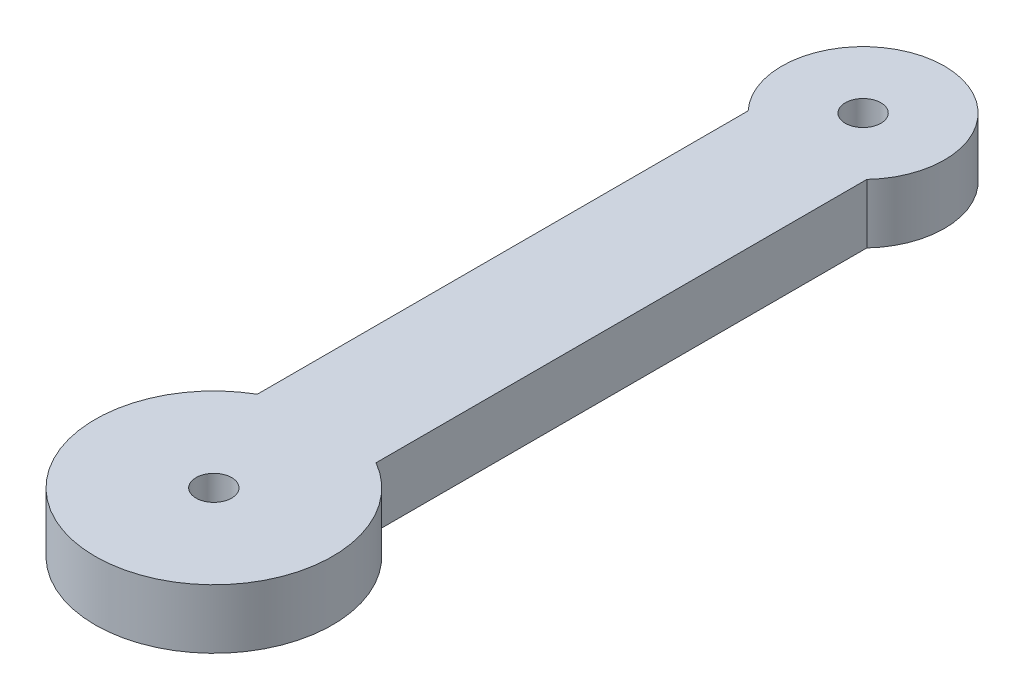
from build123d import *

# Parameters (mm, degrees)
SKETCH2_R           = 0.75
BOSS_EXTRUDE1_DEPTH = 2.5


with BuildPart() as part:
    # Sketch2 → Boss-Extrude1 (new body)
    with BuildSketch(Plane(origin=(0, 0, 0), x_dir=(1, 0, 0), z_dir=(0, 1, 0))):
        with BuildLine():
            Line((-2.5, 25), (-2.5, 4.330127019))
            ThreePointArc((-2.5, 4.330127019), (0, -5), (2.5, 4.330127019))
            Line((2.5, 4.330127019), (2.5, 25))
            ThreePointArc((2.5, 25), (0, 30.768904363), (-2.5, 25))
        make_face()
        Circle(SKETCH2_R, mode=Mode.SUBTRACT)
        with Locations((0, 27.342754867)):
            Circle(SKETCH2_R, mode=Mode.SUBTRACT)
    extrude(amount=BOSS_EXTRUDE1_DEPTH)


solid = part.part
